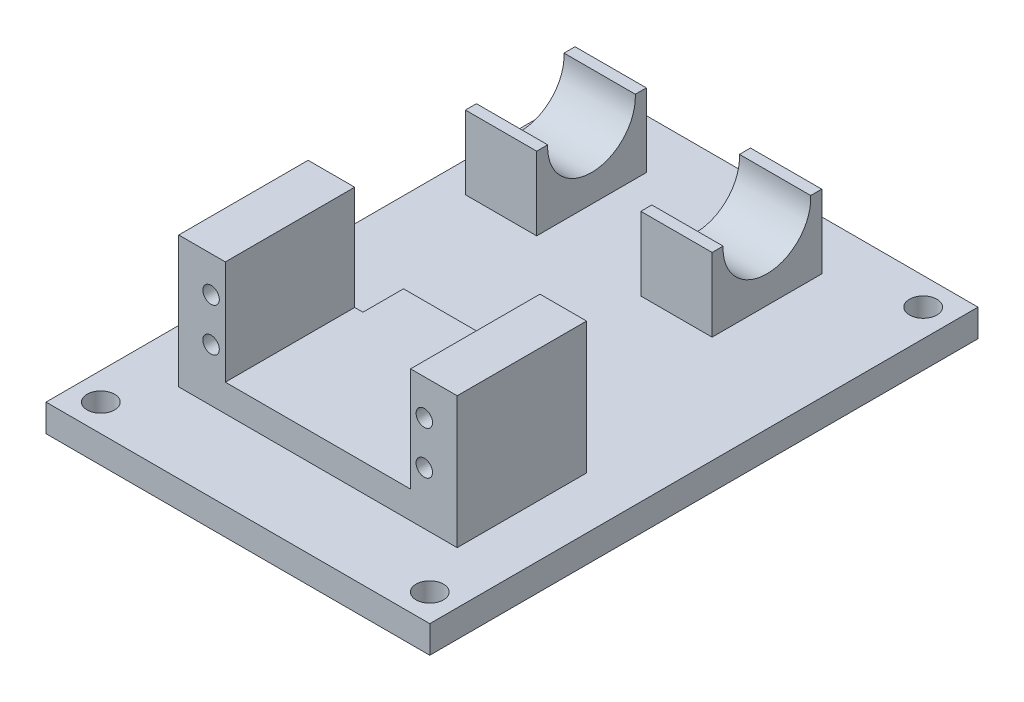
from build123d import *

# Parameters (mm, degrees)
SKETCH1_W           = 70
SKETCH1_H           = 100
BOSS_EXTRUDE1_DEPTH = 5
SKETCH2_W           = 13
SKETCH2_H           = 20
BOSS_EXTRUDE2_DEPTH = 5
SKETCH4_W           = 8.5
SKETCH4_H           = 23.6
BOSS_EXTRUDE3_DEPTH = 19
SKETCH5_R           = 1.5
CUT_EXTRUDE1_DEPTH  = 26
SKETCH6_W           = 13
SKETCH6_H           = 20
BOSS_EXTRUDE4_DEPTH = 8.385
SKETCH7_R           = 8
CUT_EXTRUDE2_DEPTH  = 63
CUT_EXTRUDE3_REACH  = 7
SKETCH8_R           = 2.5


with BuildPart() as part:
    # Sketch1 → Boss-Extrude1 (new body)
    with BuildSketch(Plane(origin=(0, 0, 0), x_dir=(1, 0, 0), z_dir=(0, 1, 0))):
        Rectangle(SKETCH1_W, SKETCH1_H)
    extrude(amount=BOSS_EXTRUDE1_DEPTH)

    # Sketch2 → Boss-Extrude2 (add)
    with BuildSketch(Plane(origin=(0, 5, 0), x_dir=(1, 0, 0), z_dir=(0, 1, 0))):
        Polygon((-15.28967138, -11.9), (-25.28967138, -11.9), (-25.28967138, -35.5), (25.5, -35.5), (25.5, -11.9), (15.5, -11.9), (15.5, -4.5), (-15.28967138, -4.5), align=None)
        with Locations((-23, 31)):
            Rectangle(SKETCH2_W, SKETCH2_H)
        with Locations((9, 31)):
            Rectangle(SKETCH2_W, SKETCH2_H)
    extrude(amount=BOSS_EXTRUDE2_DEPTH)

    # Sketch4 → Boss-Extrude3 (add)
    with BuildSketch(Plane(origin=(0, 10, 0), x_dir=(1, 0, 0), z_dir=(0, 1, 0))):
        with Locations((-21.03967138, -23.7)):
            Rectangle(SKETCH4_W, SKETCH4_H)
        with Locations((21.25, -23.7)):
            Rectangle(SKETCH4_W, SKETCH4_H)
    extrude(amount=BOSS_EXTRUDE3_DEPTH)

    # Sketch5 → Cut-Extrude1 (cut)
    with BuildSketch(Plane(origin=(0, 0, 11.9), x_dir=(-1, 0, 0), z_dir=(0, 0, -1))):
        with Locations((19.39, 22.5)):
            Circle(SKETCH5_R)
        with Locations((19.39, 14.63)):
            Circle(SKETCH5_R)
        with Locations((-19.5, 22.5)):
            Circle(SKETCH5_R)
        with Locations((-19.5, 14.63)):
            Circle(SKETCH5_R)
    extrude(amount=-CUT_EXTRUDE1_DEPTH, mode=Mode.SUBTRACT)

    # Sketch6 → Boss-Extrude4 (add)
    with BuildSketch(Plane(origin=(0, 10, 0), x_dir=(1, 0, 0), z_dir=(0, 1, 0))):
        with Locations((-23, 31)):
            Rectangle(SKETCH6_W, SKETCH6_H)
        with Locations((9, 31)):
            Rectangle(SKETCH6_W, SKETCH6_H)
    extrude(amount=BOSS_EXTRUDE4_DEPTH)

    # Sketch7 → Cut-Extrude2 (cut)
    with BuildSketch(Plane.ZY.offset(29.5)):
        with Locations((-31, 18)):
            Circle(SKETCH7_R)
    extrude(amount=-CUT_EXTRUDE2_DEPTH, mode=Mode.SUBTRACT)

    # Sketch8 → Cut-Extrude3 (cut, up to next)
    with BuildSketch(Plane(origin=(0, 5, 0), x_dir=(1, 0, 0), z_dir=(0, 1, 0)), mode=Mode.PRIVATE) as cut_extrude3_sk1:
        with Locations((30, 45)):
            Circle(SKETCH8_R)
    cut_extrude3_tool1 = extrude(cut_extrude3_sk1.sketch, amount=-CUT_EXTRUDE3_REACH, mode=Mode.PRIVATE) & part.part
    add(cut_extrude3_tool1.solids().sort_by_distance((30, 5, -45))[0], mode=Mode.SUBTRACT)
    # Sketch8 → Cut-Extrude3 (cut, up to next)
    with BuildSketch(Plane(origin=(0, 5, 0), x_dir=(1, 0, 0), z_dir=(0, 1, 0)), mode=Mode.PRIVATE) as cut_extrude3_sk2:
        with Locations((-30, 45)):
            Circle(SKETCH8_R)
    cut_extrude3_tool2 = extrude(cut_extrude3_sk2.sketch, amount=-CUT_EXTRUDE3_REACH, mode=Mode.PRIVATE) & part.part
    add(cut_extrude3_tool2.solids().sort_by_distance((-30, 5, -45))[0], mode=Mode.SUBTRACT)
    # Sketch8 → Cut-Extrude3 (cut, up to next)
    with BuildSketch(Plane(origin=(0, 5, 0), x_dir=(1, 0, 0), z_dir=(0, 1, 0)), mode=Mode.PRIVATE) as cut_extrude3_sk3:
        with Locations((-30, -45)):
            Circle(SKETCH8_R)
    cut_extrude3_tool3 = extrude(cut_extrude3_sk3.sketch, amount=-CUT_EXTRUDE3_REACH, mode=Mode.PRIVATE) & part.part
    add(cut_extrude3_tool3.solids().sort_by_distance((-30, 5, 45))[0], mode=Mode.SUBTRACT)
    # Sketch8 → Cut-Extrude3 (cut, up to next)
    with BuildSketch(Plane(origin=(0, 5, 0), x_dir=(1, 0, 0), z_dir=(0, 1, 0)), mode=Mode.PRIVATE) as cut_extrude3_sk4:
        with Locations((30, -45)):
            Circle(SKETCH8_R)
    cut_extrude3_tool4 = extrude(cut_extrude3_sk4.sketch, amount=-CUT_EXTRUDE3_REACH, mode=Mode.PRIVATE) & part.part
    add(cut_extrude3_tool4.solids().sort_by_distance((30, 5, 45))[0], mode=Mode.SUBTRACT)


solid = part.part
